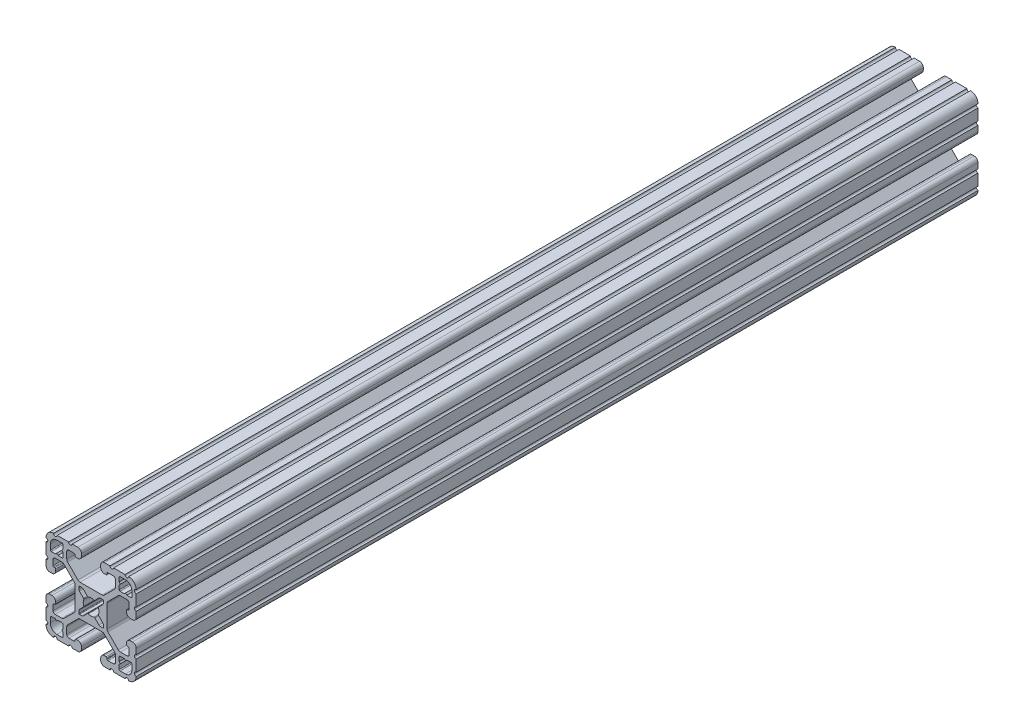
from build123d import *

# Parameters (mm, degrees)
BOSS_EXTRUDE1_DEPTH = 355.6


with BuildPart() as part:
    # Sketch1 → Boss-Extrude1 (new body)
    with BuildSketch(Plane(origin=(0, 0, -2322.576), x_dir=(-1, 0, 0), z_dir=(0, 0, -1))):
        with BuildLine():
            Line((19.05, -14.325600033), (19.05, -9.4996))
            ThreePointArc((19.05, -9.4996), (18.288, -8.7376), (19.05, -7.9756))
            Line((19.05, -7.9756), (19.05, -5.6388))
            ThreePointArc((19.05, -5.6388), (18.588751759, -4.525248241), (17.4752, -4.064))
            Line((17.4752, -4.064), (16.5608, -4.064))
            ThreePointArc((16.5608, -4.064), (15.447248241, -4.525248241), (14.986, -5.6388))
            Line((14.986, -5.6388), (14.986, -6.350014224))
            ThreePointArc((14.986, -6.350014224), (15.097592316, -6.619421908), (15.367, -6.731014224))
            Line((15.367, -6.731014224), (15.6972, -6.731014224))
            ThreePointArc((15.6972, -6.731014224), (15.966607684, -6.84260654), (16.0782, -7.112014224))
            Line((16.0782, -7.112014224), (16.0782, -9.398014224))
            ThreePointArc((16.0782, -9.398014224), (15.817817928, -10.026632152), (15.1892, -10.287014224))
            Line((15.1892, -10.287014224), (12.375630013, -10.287014224))
            ThreePointArc((12.375630013, -10.287014224), (11.889622054, -10.19034123), (11.477604401, -9.915039836))
            Line((11.477604401, -9.915039836), (7.115699788, -5.553135223))
            ThreePointArc((7.115699788, -5.553135223), (6.840398394, -5.14111757), (6.7437254, -4.655109611))
            Line((6.7437254, -4.655109611), (6.7437254, 4.655109611))
            ThreePointArc((6.7437254, 4.655109611), (6.840398394, 5.14111757), (7.115699788, 5.553135223))
            Line((7.115699788, 5.553135223), (11.477604401, 9.915039836))
            ThreePointArc((11.477604401, 9.915039836), (11.889622054, 10.19034123), (12.375630013, 10.287014224))
            Line((12.375630013, 10.287014224), (15.1892, 10.287014224))
            ThreePointArc((15.1892, 10.287014224), (15.817817928, 10.026632152), (16.0782, 9.398014224))
            Line((16.0782, 9.398014224), (16.0782, 7.112014224))
            ThreePointArc((16.0782, 7.112014224), (15.966607684, 6.84260654), (15.6972, 6.731014224))
            Line((15.6972, 6.731014224), (15.367, 6.731014224))
            ThreePointArc((15.367, 6.731014224), (15.097592316, 6.619421908), (14.986, 6.350014224))
            Line((14.986, 6.350014224), (14.986, 5.6388))
            ThreePointArc((14.986, 5.6388), (15.447248241, 4.525248241), (16.5608, 4.064))
            Line((16.5608, 4.064), (17.4752, 4.064))
            ThreePointArc((17.4752, 4.064), (18.588751759, 4.525248241), (19.05, 5.6388))
            Line((19.05, 5.6388), (19.05, 7.9756))
            ThreePointArc((19.05, 7.9756), (18.288, 8.7376), (19.05, 9.4996))
            Line((19.05, 9.4996), (19.05, 14.325599984))
            ThreePointArc((19.05, 14.325599984), (18.287999986, 15.087549208), (19.049898416, 15.849600009))
            ThreePointArc((19.049898416, 15.849600009), (18.120064036, 18.120064058), (15.849599977, 19.049898414))
            ThreePointArc((15.849599977, 19.049898414), (15.0875492, 18.288000035), (14.325600017, 19.050000016))
            Line((14.325600017, 19.050000016), (9.499600001, 19.050000016))
            ThreePointArc((9.499600001, 19.050000016), (8.737600001, 18.288000016), (7.975600001, 19.050000016))
            Line((7.975600001, 19.050000016), (5.638800016, 19.050000016))
            ThreePointArc((5.638800016, 19.050000016), (4.525248257, 18.588751775), (4.064000016, 17.475200016))
            Line((4.064000016, 17.475200016), (4.064000016, 16.5608))
            ThreePointArc((4.064000016, 16.5608), (4.525248257, 15.447248241), (5.638800016, 14.986))
            Line((5.638800016, 14.986), (6.350014224, 14.986))
            ThreePointArc((6.350014224, 14.986), (6.619421908, 15.097592316), (6.731014224, 15.367))
            Line((6.731014224, 15.367), (6.731014224, 15.6972))
            ThreePointArc((6.731014224, 15.6972), (6.84260654, 15.966607684), (7.112014224, 16.0782))
            Line((7.112014224, 16.0782), (9.398014224, 16.0782))
            ThreePointArc((9.398014224, 16.0782), (10.026632152, 15.817817928), (10.287014224, 15.1892))
            Line((10.287014224, 15.1892), (10.287014224, 12.375630013))
            ThreePointArc((10.287014224, 12.375630013), (10.19034123, 11.889622054), (9.915039836, 11.477604401))
            Line((9.915039836, 11.477604401), (5.553135223, 7.115699788))
            ThreePointArc((5.553135223, 7.115699788), (5.14111757, 6.840398394), (4.655109611, 6.7437254))
            Line((4.655109611, 6.7437254), (-4.655109611, 6.7437254))
            ThreePointArc((-4.655109611, 6.7437254), (-5.14111757, 6.840398394), (-5.553135223, 7.115699788))
            Line((-5.553135223, 7.115699788), (-9.915039836, 11.477604401))
            ThreePointArc((-9.915039836, 11.477604401), (-10.19034123, 11.889622054), (-10.287014224, 12.375630013))
            Line((-10.287014224, 12.375630013), (-10.287014224, 15.1892))
            ThreePointArc((-10.287014224, 15.1892), (-10.026632152, 15.817817928), (-9.398014224, 16.0782))
            Line((-9.398014224, 16.0782), (-7.112014224, 16.0782))
            ThreePointArc((-7.112014224, 16.0782), (-6.84260654, 15.966607684), (-6.731014224, 15.6972))
            Line((-6.731014224, 15.6972), (-6.731014224, 15.367))
            ThreePointArc((-6.731014224, 15.367), (-6.619421908, 15.097592316), (-6.350014224, 14.986))
            Line((-6.350014224, 14.986), (-5.638799984, 14.986))
            ThreePointArc((-5.638799984, 14.986), (-4.525248225, 15.447248241), (-4.063999984, 16.5608))
            Line((-4.063999984, 16.5608), (-4.063999984, 17.475200016))
            ThreePointArc((-4.063999984, 17.475200016), (-4.525248225, 18.588751775), (-5.638799984, 19.050000016))
            Line((-5.638799984, 19.050000016), (-7.975599999, 19.050000016))
            ThreePointArc((-7.975599999, 19.050000016), (-8.737599999, 18.288000016), (-9.499599999, 19.050000016))
            Line((-9.499599999, 19.050000016), (-14.325599999, 19.050000016))
            ThreePointArc((-14.325599999, 19.050000016), (-15.087549199, 18.288000018), (-15.849599993, 19.049898416))
            ThreePointArc((-15.849599993, 19.049898416), (-18.120064042, 18.120064036), (-19.049898398, 15.849599976))
            ThreePointArc((-19.049898398, 15.849599976), (-18.288000019, 15.087549199), (-19.05, 14.325600017))
            Line((-19.05, 14.325600017), (-19.05, 9.4996))
            ThreePointArc((-19.05, 9.4996), (-18.288, 8.7376), (-19.05, 7.9756))
            Line((-19.05, 7.9756), (-19.05, 5.6388))
            ThreePointArc((-19.05, 5.6388), (-18.588751759, 4.525248241), (-17.4752, 4.064))
            Line((-17.4752, 4.064), (-16.5608, 4.064))
            ThreePointArc((-16.5608, 4.064), (-15.447248241, 4.525248241), (-14.986, 5.6388))
            Line((-14.986, 5.6388), (-14.986, 6.350014224))
            ThreePointArc((-14.986, 6.350014224), (-15.097592316, 6.619421908), (-15.367, 6.731014224))
            Line((-15.367, 6.731014224), (-15.6972, 6.731014224))
            ThreePointArc((-15.6972, 6.731014224), (-15.966607684, 6.84260654), (-16.0782, 7.112014224))
            Line((-16.0782, 7.112014224), (-16.0782, 9.398014224))
            ThreePointArc((-16.0782, 9.398014224), (-15.817817928, 10.026632152), (-15.1892, 10.287014224))
            Line((-15.1892, 10.287014224), (-12.375630013, 10.287014224))
            ThreePointArc((-12.375630013, 10.287014224), (-11.889622054, 10.19034123), (-11.477604401, 9.915039836))
            Line((-11.477604401, 9.915039836), (-7.115699788, 5.553135223))
            ThreePointArc((-7.115699788, 5.553135223), (-6.840398394, 5.14111757), (-6.7437254, 4.655109611))
            Line((-6.7437254, 4.655109611), (-6.7437254, -4.655109611))
            ThreePointArc((-6.7437254, -4.655109611), (-6.840398394, -5.14111757), (-7.115699788, -5.553135223))
            Line((-7.115699788, -5.553135223), (-11.477604401, -9.915039836))
            ThreePointArc((-11.477604401, -9.915039836), (-11.889622054, -10.19034123), (-12.375630013, -10.287014224))
            Line((-12.375630013, -10.287014224), (-15.1892, -10.287014224))
            ThreePointArc((-15.1892, -10.287014224), (-15.817817928, -10.026632152), (-16.0782, -9.398014224))
            Line((-16.0782, -9.398014224), (-16.0782, -7.112014224))
            ThreePointArc((-16.0782, -7.112014224), (-15.966607684, -6.84260654), (-15.6972, -6.731014224))
            Line((-15.6972, -6.731014224), (-15.367, -6.731014224))
            ThreePointArc((-15.367, -6.731014224), (-15.097592316, -6.619421908), (-14.986, -6.350014224))
            Line((-14.986, -6.350014224), (-14.986, -5.6388))
            ThreePointArc((-14.986, -5.6388), (-15.447248241, -4.525248241), (-16.5608, -4.064))
            Line((-16.5608, -4.064), (-17.4752, -4.064))
            ThreePointArc((-17.4752, -4.064), (-18.588751759, -4.525248241), (-19.05, -5.6388))
            Line((-19.05, -5.6388), (-19.05, -7.9756))
            ThreePointArc((-19.05, -7.9756), (-18.288, -8.7376), (-19.05, -9.4996))
            Line((-19.05, -9.4996), (-19.05, -14.3256))
            ThreePointArc((-19.05, -14.3256), (-18.288000002, -15.0875492), (-19.0498984, -15.849599993))
            ThreePointArc((-19.0498984, -15.849599993), (-18.120064019, -18.120064043), (-15.84959996, -19.049898399))
            ThreePointArc((-15.84959996, -19.049898399), (-15.087549183, -18.288000019), (-14.325600001, -19.050000001))
            Line((-14.325600001, -19.050000001), (-9.499599984, -19.050000001))
            ThreePointArc((-9.499599984, -19.050000001), (-8.737599984, -18.288000001), (-7.975599984, -19.050000001))
            Line((-7.975599984, -19.050000001), (-5.638799984, -19.050000001))
            ThreePointArc((-5.638799984, -19.050000001), (-4.525248225, -18.58875176), (-4.063999984, -17.475200001))
            Line((-4.063999984, -17.475200001), (-4.063999984, -16.5608))
            ThreePointArc((-4.063999984, -16.5608), (-4.525248225, -15.447248241), (-5.638799984, -14.986))
            Line((-5.638799984, -14.986), (-6.350014224, -14.986))
            ThreePointArc((-6.350014224, -14.986), (-6.619421908, -15.097592316), (-6.731014224, -15.367))
            Line((-6.731014224, -15.367), (-6.731014224, -15.6972))
            ThreePointArc((-6.731014224, -15.6972), (-6.84260654, -15.966607684), (-7.112014224, -16.0782))
            Line((-7.112014224, -16.0782), (-9.398014224, -16.0782))
            ThreePointArc((-9.398014224, -16.0782), (-10.026632152, -15.817817928), (-10.287014224, -15.1892))
            Line((-10.287014224, -15.1892), (-10.287014224, -12.375630013))
            ThreePointArc((-10.287014224, -12.375630013), (-10.19034123, -11.889622054), (-9.915039836, -11.477604401))
            Line((-9.915039836, -11.477604401), (-5.553135223, -7.115699788))
            ThreePointArc((-5.553135223, -7.115699788), (-5.14111757, -6.840398394), (-4.655109611, -6.7437254))
            Line((-4.655109611, -6.7437254), (4.655109611, -6.7437254))
            ThreePointArc((4.655109611, -6.7437254), (5.14111757, -6.840398394), (5.553135223, -7.115699788))
            Line((5.553135223, -7.115699788), (9.915039836, -11.477604401))
            ThreePointArc((9.915039836, -11.477604401), (10.19034123, -11.889622054), (10.287014224, -12.375630013))
            Line((10.287014224, -12.375630013), (10.287014224, -15.1892))
            ThreePointArc((10.287014224, -15.1892), (10.026632152, -15.817817928), (9.398014224, -16.0782))
            Line((9.398014224, -16.0782), (7.112014224, -16.0782))
            ThreePointArc((7.112014224, -16.0782), (6.84260654, -15.966607684), (6.731014224, -15.6972))
            Line((6.731014224, -15.6972), (6.731014224, -15.367))
            ThreePointArc((6.731014224, -15.367), (6.619421908, -15.097592316), (6.350014224, -14.986))
            Line((6.350014224, -14.986), (5.638800016, -14.986))
            ThreePointArc((5.638800016, -14.986), (4.525248257, -15.447248241), (4.064000016, -16.5608))
            Line((4.064000016, -16.5608), (4.064000016, -17.475200001))
            ThreePointArc((4.064000016, -17.475200001), (4.525248257, -18.58875176), (5.638800016, -19.050000001))
            Line((5.638800016, -19.050000001), (7.975600016, -19.050000001))
            ThreePointArc((7.975600016, -19.050000001), (8.737600016, -18.288000001), (9.499600016, -19.050000001))
            Line((9.499600016, -19.050000001), (14.325600016, -19.050000001))
            ThreePointArc((14.325600016, -19.050000001), (15.087549216, -18.288000002), (15.849600009, -19.0498984))
            ThreePointArc((15.849600009, -19.0498984), (18.120064059, -18.12006402), (19.049898415, -15.849599961))
            ThreePointArc((19.049898415, -15.849599961), (18.288000034, -15.087549207), (19.05, -14.325600033))
        make_face()
        with BuildLine():
            Line((17.246614224, 14.452614224), (17.246614224, 12.242814224))
            ThreePointArc((17.246614224, 12.242814224), (17.135021908, 11.97340654), (16.865614224, 11.861814224))
            Line((16.865614224, 11.861814224), (15.092694224, 11.861814224))
            Line((15.092694224, 11.861814224), (14.554214224, 12.400294224))
            Line((14.554214224, 12.400294224), (14.015734224, 11.861814224))
            Line((14.015734224, 11.861814224), (12.242814224, 11.861814224))
            ThreePointArc((12.242814224, 11.861814224), (11.97340654, 11.97340654), (11.861814224, 12.242814224))
            Line((11.861814224, 12.242814224), (11.861814224, 14.015734224))
            Line((11.861814224, 14.015734224), (12.400294224, 14.554214224))
            Line((12.400294224, 14.554214224), (11.861814224, 15.092694224))
            Line((11.861814224, 15.092694224), (11.861814224, 16.865614224))
            ThreePointArc((11.861814224, 16.865614224), (11.97340654, 17.135021908), (12.242814224, 17.246614224))
            Line((12.242814224, 17.246614224), (14.452614224, 17.246614224))
            ThreePointArc((14.452614224, 17.246614224), (16.428270571, 16.428270571), (17.246614224, 14.452614224))
        make_face(mode=Mode.SUBTRACT)
        with BuildLine():
            Line((17.246614224, -12.242814224), (17.246614224, -14.452614224))
            ThreePointArc((17.246614224, -14.452614224), (16.428270571, -16.428270571), (14.452614224, -17.246614224))
            Line((14.452614224, -17.246614224), (12.242814224, -17.246614224))
            ThreePointArc((12.242814224, -17.246614224), (11.97340654, -17.135021908), (11.861814224, -16.865614224))
            Line((11.861814224, -16.865614224), (11.861814224, -15.092694224))
            Line((11.861814224, -15.092694224), (12.400294224, -14.554214224))
            Line((12.400294224, -14.554214224), (11.861814224, -14.015734224))
            Line((11.861814224, -14.015734224), (11.861814224, -12.242814224))
            ThreePointArc((11.861814224, -12.242814224), (11.97340654, -11.97340654), (12.242814224, -11.861814224))
            Line((12.242814224, -11.861814224), (14.015734224, -11.861814224))
            Line((14.015734224, -11.861814224), (14.554214224, -12.400294224))
            Line((14.554214224, -12.400294224), (15.092694224, -11.861814224))
            Line((15.092694224, -11.861814224), (16.865614224, -11.861814224))
            ThreePointArc((16.865614224, -11.861814224), (17.135021908, -11.97340654), (17.246614224, -12.242814224))
        make_face(mode=Mode.SUBTRACT)
        with BuildLine():
            Line((5.1689, -3.920689755), (5.1689, -4.9149))
            ThreePointArc((5.1689, -4.9149), (5.094505122, -5.094505122), (4.9149, -5.1689))
            Line((4.9149, -5.1689), (3.920689755, -5.1689))
            ThreePointArc((3.920689755, -5.1689), (3.580484184, -5.101228904), (3.292071827, -4.908517928))
            Line((3.292071827, -4.908517928), (1.582347442, -3.198793543))
            ThreePointArc((1.582347442, -3.198793543), (1.393016011, -3.095711236), (1.178048687, -3.111879183))
            ThreePointArc((1.178048687, -3.111879183), (0, -3.3274), (-1.178048687, -3.111879183))
            ThreePointArc((-1.178048687, -3.111879183), (-1.393016011, -3.095711236), (-1.582347442, -3.198793543))
            Line((-1.582347442, -3.198793543), (-3.292071827, -4.908517928))
            ThreePointArc((-3.292071827, -4.908517928), (-3.580484184, -5.101228904), (-3.920689755, -5.1689))
            Line((-3.920689755, -5.1689), (-4.9149, -5.1689))
            ThreePointArc((-4.9149, -5.1689), (-5.094505122, -5.094505122), (-5.1689, -4.9149))
            Line((-5.1689, -4.9149), (-5.1689, -3.920689755))
            ThreePointArc((-5.1689, -3.920689755), (-5.101228904, -3.580484184), (-4.908517928, -3.292071827))
            Line((-4.908517928, -3.292071827), (-3.198793543, -1.582347442))
            ThreePointArc((-3.198793543, -1.582347442), (-3.095711236, -1.393016011), (-3.111879183, -1.178048687))
            ThreePointArc((-3.111879183, -1.178048687), (-3.3274, 0), (-3.111879183, 1.178048687))
            ThreePointArc((-3.111879183, 1.178048687), (-3.095711236, 1.393016011), (-3.198793543, 1.582347442))
            Line((-3.198793543, 1.582347442), (-4.908517928, 3.292071827))
            ThreePointArc((-4.908517928, 3.292071827), (-5.101228904, 3.580484184), (-5.1689, 3.920689755))
            Line((-5.1689, 3.920689755), (-5.1689, 4.9149))
            ThreePointArc((-5.1689, 4.9149), (-5.094505122, 5.094505122), (-4.9149, 5.1689))
            Line((-4.9149, 5.1689), (-3.920689755, 5.1689))
            ThreePointArc((-3.920689755, 5.1689), (-3.580484184, 5.101228904), (-3.292071827, 4.908517928))
            Line((-3.292071827, 4.908517928), (-1.582347442, 3.198793543))
            ThreePointArc((-1.582347442, 3.198793543), (-1.393016011, 3.095711236), (-1.178048687, 3.111879183))
            ThreePointArc((-1.178048687, 3.111879183), (0, 3.3274), (1.178048687, 3.111879183))
            ThreePointArc((1.178048687, 3.111879183), (1.393016011, 3.095711236), (1.582347442, 3.198793543))
            Line((1.582347442, 3.198793543), (3.292071827, 4.908517928))
            ThreePointArc((3.292071827, 4.908517928), (3.580484184, 5.101228904), (3.920689755, 5.1689))
            Line((3.920689755, 5.1689), (4.9149, 5.1689))
            ThreePointArc((4.9149, 5.1689), (5.094505122, 5.094505122), (5.1689, 4.9149))
            Line((5.1689, 4.9149), (5.1689, 3.920689755))
            ThreePointArc((5.1689, 3.920689755), (5.101228904, 3.580484184), (4.908517928, 3.292071827))
            Line((4.908517928, 3.292071827), (3.198793543, 1.582347442))
            ThreePointArc((3.198793543, 1.582347442), (3.095711236, 1.393016011), (3.111879183, 1.178048687))
            ThreePointArc((3.111879183, 1.178048687), (3.3274, 0), (3.111879183, -1.178048687))
            ThreePointArc((3.111879183, -1.178048687), (3.095711236, -1.393016011), (3.198793543, -1.582347442))
            Line((3.198793543, -1.582347442), (4.908517928, -3.292071827))
            ThreePointArc((4.908517928, -3.292071827), (5.101228904, -3.580484184), (5.1689, -3.920689755))
        make_face(mode=Mode.SUBTRACT)
        with BuildLine():
            Line((-11.861814224, -12.242814224), (-11.861814224, -14.015734224))
            Line((-11.861814224, -14.015734224), (-12.400294224, -14.554214224))
            Line((-12.400294224, -14.554214224), (-11.861814224, -15.092694224))
            Line((-11.861814224, -15.092694224), (-11.861814224, -16.865614224))
            ThreePointArc((-11.861814224, -16.865614224), (-11.97340654, -17.135021908), (-12.242814224, -17.246614224))
            Line((-12.242814224, -17.246614224), (-14.452614224, -17.246614224))
            ThreePointArc((-14.452614224, -17.246614224), (-16.428270571, -16.428270571), (-17.246614224, -14.452614224))
            Line((-17.246614224, -14.452614224), (-17.246614224, -12.242814224))
            ThreePointArc((-17.246614224, -12.242814224), (-17.135021908, -11.97340654), (-16.865614224, -11.861814224))
            Line((-16.865614224, -11.861814224), (-15.092694224, -11.861814224))
            Line((-15.092694224, -11.861814224), (-14.554214224, -12.400294224))
            Line((-14.554214224, -12.400294224), (-14.015734224, -11.861814224))
            Line((-14.015734224, -11.861814224), (-12.242814224, -11.861814224))
            ThreePointArc((-12.242814224, -11.861814224), (-11.97340654, -11.97340654), (-11.861814224, -12.242814224))
        make_face(mode=Mode.SUBTRACT)
        with BuildLine():
            Line((-11.861814224, 16.865614224), (-11.861814224, 15.092694224))
            Line((-11.861814224, 15.092694224), (-12.400294224, 14.554214224))
            Line((-12.400294224, 14.554214224), (-11.861814224, 14.015734224))
            Line((-11.861814224, 14.015734224), (-11.861814224, 12.242814224))
            ThreePointArc((-11.861814224, 12.242814224), (-11.97340654, 11.97340654), (-12.242814224, 11.861814224))
            Line((-12.242814224, 11.861814224), (-14.015734224, 11.861814224))
            Line((-14.015734224, 11.861814224), (-14.554214224, 12.400294224))
            Line((-14.554214224, 12.400294224), (-15.092694224, 11.861814224))
            Line((-15.092694224, 11.861814224), (-16.865614224, 11.861814224))
            ThreePointArc((-16.865614224, 11.861814224), (-17.135021908, 11.97340654), (-17.246614224, 12.242814224))
            Line((-17.246614224, 12.242814224), (-17.246614224, 14.452614224))
            ThreePointArc((-17.246614224, 14.452614224), (-16.428270571, 16.428270571), (-14.452614224, 17.246614224))
            Line((-14.452614224, 17.246614224), (-12.242814224, 17.246614224))
            ThreePointArc((-12.242814224, 17.246614224), (-11.97340654, 17.135021908), (-11.861814224, 16.865614224))
        make_face(mode=Mode.SUBTRACT)
    extrude(amount=-BOSS_EXTRUDE1_DEPTH)


solid = part.part
